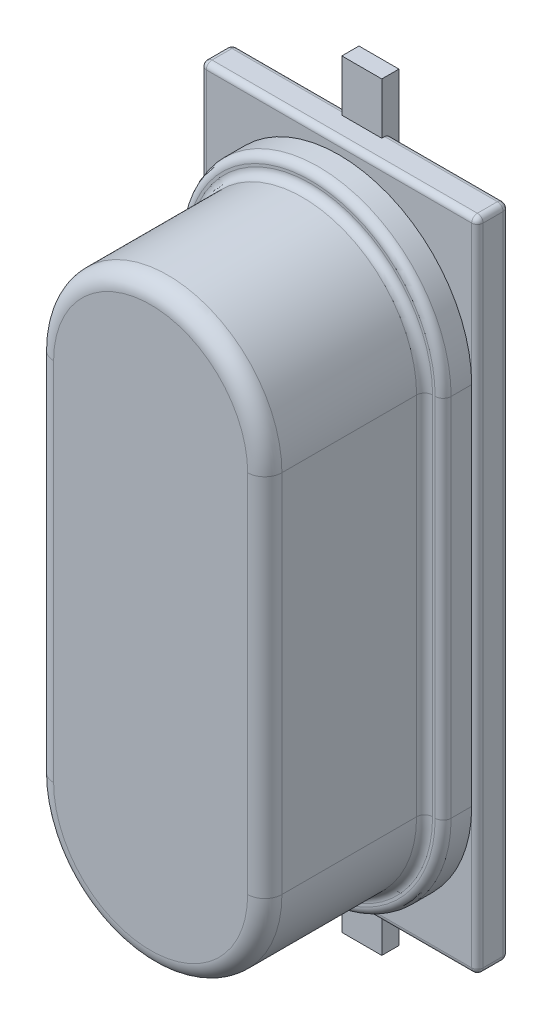
from build123d import *

# Parameters (mm, degrees)
BOSS_EXTRUDE1_START = 0.7
BOSS_EXTRUDE1_DEPTH = 0.5
BOSS_EXTRUDE2_DEPTH = 2.8
FILLET2_R           = 0.14
FILLET_3_R          = 0.3
SKETCH_3_W          = 4.85
SKETCH_3_H          = 11.5
EXTRUDE_3_DEPTH     = 0.55
FILLET_4_R          = 0.1
SKETCH_1_W          = 0.7
SKETCH_1_H          = 4.21
EXTRUDE_4_DEPTH     = 0.3
EXTRUDE_4_2_DEPTH   = 0.3


with BuildPart() as part:
    # Sketch2 → Boss-Extrude1 (new body)
    with BuildSketch(Plane.XY.offset(BOSS_EXTRUDE1_START)):
        with BuildLine():
            Line((2.325, 3.2), (2.325, -3.2))
            ThreePointArc((2.325, -3.2), (0, -5.525), (-2.325, -3.2))
            Line((-2.325, -3.2), (-2.325, 3.2))
            ThreePointArc((-2.325, 3.2), (0, 5.525), (2.325, 3.2))
        make_face()
    extrude(amount=BOSS_EXTRUDE1_DEPTH)

    # Sketch3 → Boss-Extrude2 (add)
    with BuildSketch(Plane.XY.offset(1.2)):
        with BuildLine():
            Line((-2, -3.2), (-2, 3.2))
            ThreePointArc((-2, 3.2), (0, 5.2), (2, 3.2))
            Line((2, 3.2), (2, -3.2))
            ThreePointArc((2, -3.2), (0, -5.2), (-2, -3.2))
        make_face()
    extrude(amount=BOSS_EXTRUDE2_DEPTH)

    # Fillet2
    fillet2_edges = [part.edges().sort_by_distance(p)[0] for p in [
        (0, -5.525, 1.2),
        (2.325, 0, 1.2),
        (0, -5.2, 1.2),
        (2, 0, 1.2),
        (0, 5.2, 1.2),
        (-2, 0, 1.2),
        (0, 5.525, 1.2),
        (-2.325, 0, 1.2),
    ]]
    fillet(fillet2_edges, radius=FILLET2_R)

    # Скругление3
    fillet_3_edges = [part.edges().sort_by_distance(p)[0] for p in [
        (0, -5.2, 4),
        (2, 0, 4),
        (0, 5.2, 4),
        (-2, 0, 4),
    ]]
    fillet(fillet_3_edges, radius=FILLET_3_R)


with BuildPart() as body_2:
    # Эскиз3 → Бобышка-Вытянуть3 (new body)
    with BuildSketch(Plane.XY.offset(0.7)):
        Rectangle(SKETCH_3_W, SKETCH_3_H)
    extrude(amount=-EXTRUDE_3_DEPTH)

    # Скругление4
    fillet_4_edges = [body_2.edges().sort_by_distance(p)[0] for p in [
        (2.425, 0, 0.15),
        (0, 5.75, 0.15),
        (-2.425, 0, 0.15),
        (0, 5.75, 0.7),
        (2.425, 0, 0.7),
        (0, -5.75, 0.7),
        (-2.425, 0, 0.7),
        (0, -5.75, 0.15),
        (-2.425, 5.75, 0.425),
        (2.425, 5.75, 0.425),
        (2.425, -5.75, 0.425),
        (-2.425, -5.75, 0.425),
    ]]
    fillet(fillet_4_edges, radius=FILLET_4_R)


with BuildPart() as body_3:
    # Эскиз1 → Бобышка-Вытянуть4 (new body)
    with BuildSketch(Plane(origin=(0, 0, 0), x_dir=(-1, 0, 0), z_dir=(0, 0, -1))):
        with Locations((0, -4.545)):
            Rectangle(SKETCH_1_W, SKETCH_1_H)
    extrude(amount=-EXTRUDE_4_DEPTH)


with BuildPart() as body_4:
    # Эскиз1 → Extrude 4 2 (new body)
    with BuildSketch(Plane(origin=(0, 0, 0), x_dir=(-1, 0, 0), z_dir=(0, 0, -1))):
        with Locations((0, 4.545)):
            Rectangle(SKETCH_1_W, SKETCH_1_H)
    extrude(amount=-EXTRUDE_4_2_DEPTH)


solid = Compound([part.part, body_2.part, body_3.part, body_4.part])
